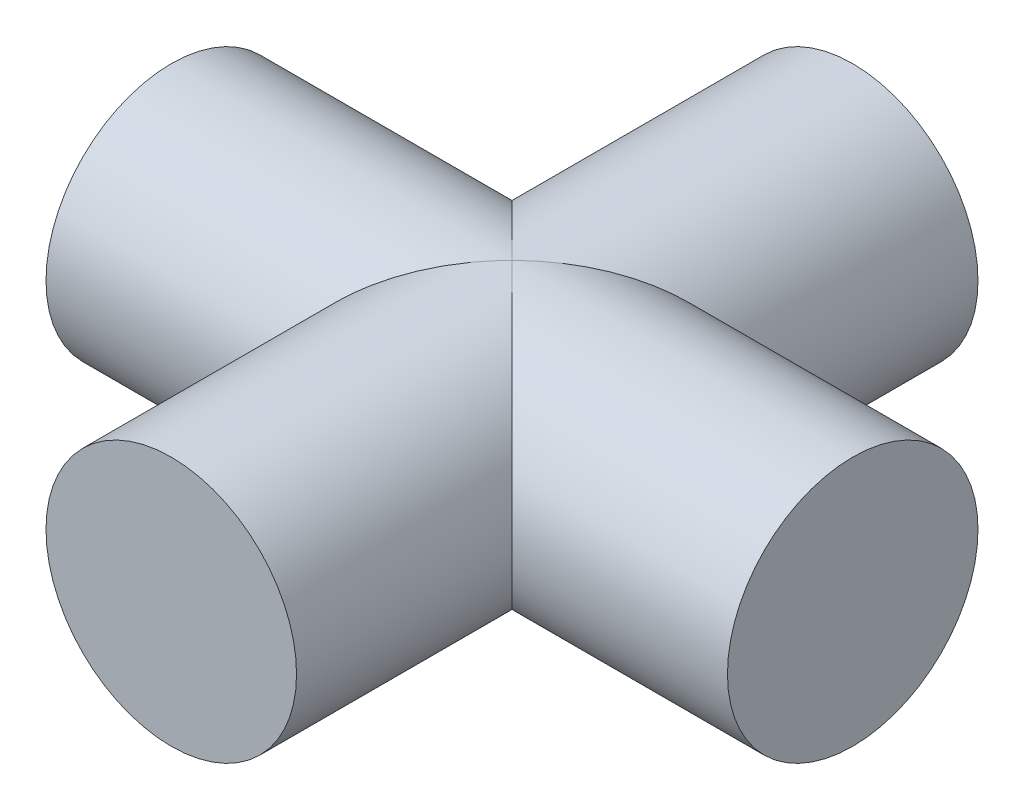
from build123d import *

# Parameters (mm, degrees)
SKETCH1_R                = 12.5
BOSS_EXTRUDE1_DEPTH      = 68
BOSS_EXTRUDE2_DEPTH      = 34
BOSS_EXTRUDE2_DEPTH_BACK = 34
SKETCH2_R                = 12.5


with BuildPart() as part:
    # Sketch1 → Boss-Extrude1 (new body)
    with BuildSketch(Plane.XY):
        Circle(SKETCH1_R)
    extrude(amount=BOSS_EXTRUDE1_DEPTH)

    # Sketch2 → Boss-Extrude2 (add, two sides: drawn at the far end of the back side and taken through both)
    with BuildSketch(Plane(origin=(0, 0, 0), x_dir=(0, 0, -1), z_dir=(1, 0, 0)).offset(-BOSS_EXTRUDE2_DEPTH_BACK)):
        with Locations((-34, 0)):
            Circle(SKETCH2_R)
    extrude(amount=BOSS_EXTRUDE2_DEPTH + BOSS_EXTRUDE2_DEPTH_BACK)


solid = part.part
